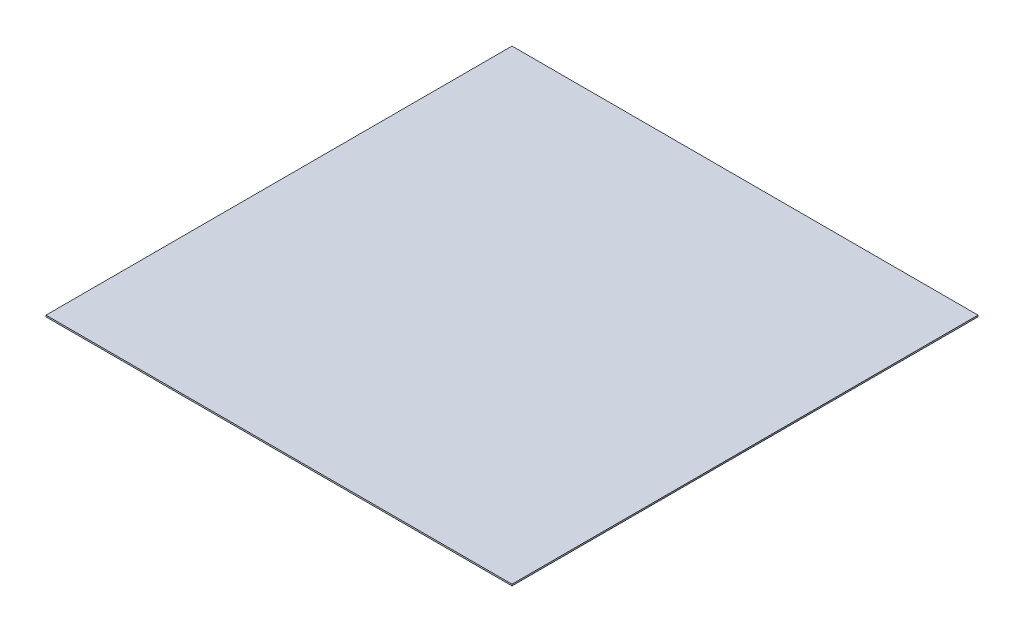
from build123d import *

# Parameters (mm, degrees)
SKETCH1_W           = 30000
SKETCH1_H           = 30000
BOSS_EXTRUDE1_DEPTH = 100
SKETCH2_W           = 30000
SKETCH2_H           = 30000
BOSS_EXTRUDE2_DEPTH = 100


with BuildPart() as part:
    # Sketch1 → Boss-Extrude1 (new body)
    with BuildSketch(Plane(origin=(0, 0, 0), x_dir=(1, 0, 0), z_dir=(0, 1, 0))):
        Rectangle(SKETCH1_W, SKETCH1_H)
    extrude(amount=BOSS_EXTRUDE1_DEPTH)


with BuildPart() as body_2:
    # Sketch2 → Boss-Extrude2 (new body)
    with BuildSketch(Plane(origin=(0, 100, 0), x_dir=(1, 0, 0), z_dir=(0, 1, 0))):
        Rectangle(SKETCH2_W, SKETCH2_H)
    extrude(amount=-BOSS_EXTRUDE2_DEPTH)


solid = Compound([part.part, body_2.part])
